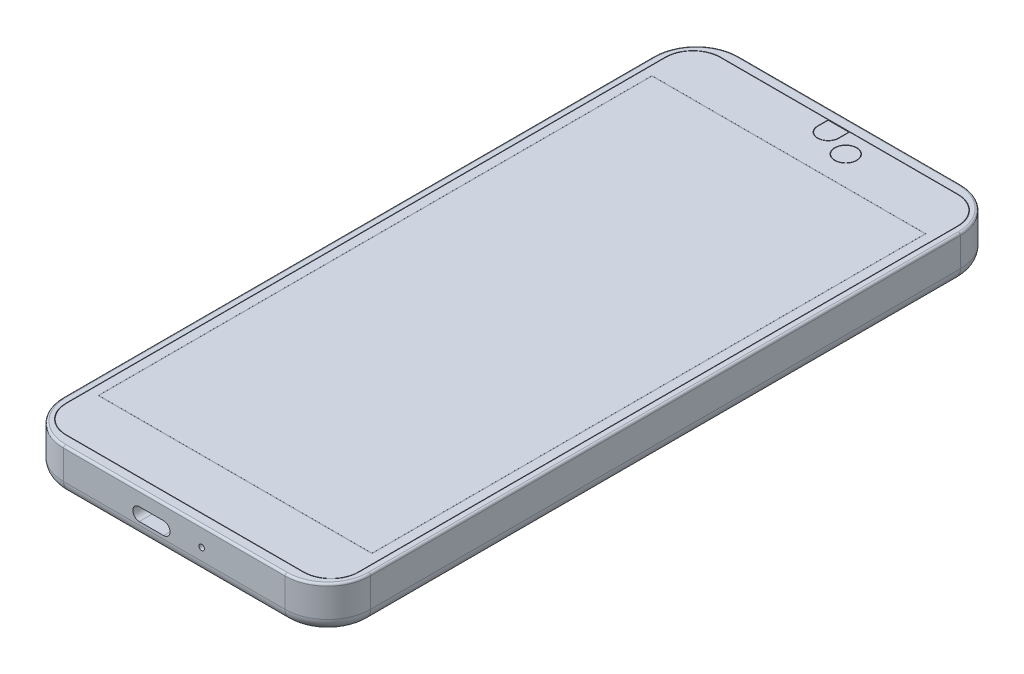
from build123d import *

# Parameters (mm, degrees)
SKIZZE1_W                            = 71.8
SKIZZE1_H                            = 158
AUFSATZ_LINEAR_AUSTRAGEN1_DEPTH      = 10.25
VERRUNDUNG1_R                        = 10
VERRUNDUNG2_R                        = 3
VERRUNDUNG3_R                        = 0.5
SCHNITT_LINEAR_AUSTRAGEN_D_NN1_DEPTH = 0.5
SCHNITT_LINEAR_AUSTRAGEN_D_NN2_DEPTH = 0.5
SKIZZE4_R                            = 2.6
SKIZZE4_R_2                          = 2.5
SCHNITT_LINEAR_AUSTRAGEN_D_NN3_DEPTH = 0.5
AUFSATZ_LINEAR_AUSTRAGEN2_DEPTH      = 0.5
SKIZZE6_R                            = 1.875
SKIZZE6_R_2                          = 0.65
SCHNITT_LINEAR_AUSTRAGEN1_DEPTH      = 25
SKIZZE7_R                            = 0.65
SCHNITT_LINEAR_AUSTRAGEN2_DEPTH      = 7
SKIZZE8_R                            = 5.25
SCHNITT_LINEAR_AUSTRAGEN3_DEPTH      = 0.9
FASE1_SIZE                           = 0.8
SCHNITT_LINEAR_AUSTRAGEN4_DEPTH      = 0.3
FASE2_SIZE                           = 0.2
SKIZZE10_W                           = 64.08
SKIZZE10_H                           = 129.6
SKIZZE10_W_2                         = 63.88
SKIZZE10_H_2                         = 129.4
SCHNITT_LINEAR_AUSTRAGEN_D_NN4_DEPTH = 0.01
SCHNITT_LINEAR_AUSTRAGEN5_DEPTH      = 2


with BuildPart() as part:
    # Skizze1 → Aufsatz-Linear austragen1 (new body)
    with BuildSketch(Plane(origin=(0, 0, 0), x_dir=(1, 0, 0), z_dir=(0, 1, 0))):
        Rectangle(SKIZZE1_W, SKIZZE1_H)
    extrude(amount=AUFSATZ_LINEAR_AUSTRAGEN1_DEPTH)

    # Verrundung1
    verrundung1_edges = [part.edges().sort_by_distance(p)[0] for p in [
        (35.9, 5.125, 79),
        (-35.9, 5.125, 79),
        (-35.9, 5.125, -79),
        (35.9, 5.125, -79),
    ]]
    fillet(verrundung1_edges, radius=VERRUNDUNG1_R)

    # Verrundung2
    verrundung2_edges = [part.edges().sort_by_distance(p)[0] for p in [
        (-35.9, 0, 0),
        (35.9, 0, 0),
        (0, 0, 79),
        (0, 0, -79),
        (32.971067812, 0, 76.071067812),
        (-32.971067812, 0, 76.071067812),
        (32.971067812, 0, -76.071067812),
        (-32.971067812, 0, -76.071067812),
    ]]
    fillet(verrundung2_edges, radius=VERRUNDUNG2_R)

    # Verrundung3
    verrundung3_edges = [part.edges().sort_by_distance(p)[0] for p in [
        (-35.9, 10.25, 0),
        (0, 10.25, -79),
        (35.9, 10.25, 0),
        (0, 10.25, 79),
        (32.971067812, 10.25, 76.071067812),
        (-32.971067812, 10.25, 76.071067812),
        (32.971067812, 10.25, -76.071067812),
        (-32.971067812, 10.25, -76.071067812),
    ]]
    fillet(verrundung3_edges, radius=VERRUNDUNG3_R)

    # Skizze2 → Schnitt-Linear-Austragen-Dünn1 (cut)
    with BuildSketch(Plane(origin=(0, 10.25, 0), x_dir=(1, 0, 0), z_dir=(0, 1, 0))):
        with BuildLine():
            Line((-27.75, 76.575), (27.75, 76.575))
            ThreePointArc((27.75, 76.575), (32.346194078, 74.671194078), (34.25, 70.075))
            Line((34.25, 70.075), (34.25, -70.075))
            ThreePointArc((34.25, -70.075), (32.346194078, -74.671194078), (27.75, -76.575))
            Line((27.75, -76.575), (-27.75, -76.575))
            ThreePointArc((-27.75, -76.575), (-32.346194078, -74.671194078), (-34.25, -70.075))
            Line((-34.25, -70.075), (-34.25, 70.075))
            ThreePointArc((-34.25, 70.075), (-32.346194078, 74.671194078), (-27.75, 76.575))
        make_face()
        with BuildLine():
            Line((-27.75, 76.475), (27.75, 76.475))
            ThreePointArc((27.75, 76.475), (32.2754834, 74.6004834), (34.15, 70.075))
            Line((34.15, 70.075), (34.15, -70.075))
            ThreePointArc((34.15, -70.075), (32.2754834, -74.6004834), (27.75, -76.475))
            Line((27.75, -76.475), (-27.75, -76.475))
            ThreePointArc((-27.75, -76.475), (-32.2754834, -74.6004834), (-34.15, -70.075))
            Line((-34.15, -70.075), (-34.15, 70.075))
            ThreePointArc((-34.15, 70.075), (-32.2754834, 74.6004834), (-27.75, 76.475))
        make_face(mode=Mode.SUBTRACT)
    extrude(amount=-SCHNITT_LINEAR_AUSTRAGEN_D_NN1_DEPTH, mode=Mode.SUBTRACT)

    # Skizze3 → Schnitt-Linear-Austragen-Dünn2 (cut)
    with BuildSketch(Plane(origin=(0, 10.25, 0), x_dir=(1, 0, 0), z_dir=(0, 1, 0))):
        with BuildLine():
            Line((-0.01, 71.475), (0.01, 71.475))
            ThreePointArc((0.01, 71.475), (1.770695885, 72.204304115), (2.5, 73.965))
            Line((2.5, 73.965), (2.5, 76.475))
            Line((2.5, 76.475), (-2.5, 76.475))
            Line((-2.5, 76.475), (-2.5, 73.965))
            ThreePointArc((-2.5, 73.965), (-1.770695885, 72.204304115), (-0.01, 71.475))
        make_face()
        with BuildLine():
            Line((-0.01, 71.575), (0.01, 71.575))
            ThreePointArc((0.01, 71.575), (1.699985207, 72.275014793), (2.4, 73.965))
            Line((2.4, 73.965), (2.4, 76.375))
            Line((2.4, 76.375), (-2.4, 76.375))
            Line((-2.4, 76.375), (-2.4, 73.965))
            ThreePointArc((-2.4, 73.965), (-1.699985207, 72.275014793), (-0.01, 71.575))
        make_face(mode=Mode.SUBTRACT)
    extrude(amount=-SCHNITT_LINEAR_AUSTRAGEN_D_NN2_DEPTH, mode=Mode.SUBTRACT)

    # Skizze4 → Schnitt-Linear-Austragen-Dünn3 (cut)
    with BuildSketch(Plane(origin=(0, 10.25, 0), x_dir=(1, 0, 0), z_dir=(0, 1, 0))):
        with Locations((6.5, 71.575)):
            Circle(SKIZZE4_R)
        with Locations((6.5, 71.575)):
            Circle(SKIZZE4_R_2, mode=Mode.SUBTRACT)
    extrude(amount=-SCHNITT_LINEAR_AUSTRAGEN_D_NN3_DEPTH, mode=Mode.SUBTRACT)

    # Skizze5 → Aufsatz-Linear austragen2 (add)
    with BuildSketch(Plane.ZY.offset(35.9)):
        with BuildLine():
            Line((-45.7, 4.61), (-36.1, 4.61))
            Line((-36.1, 4.61), (-36.1, 7.25))
            Line((-36.1, 7.25), (-45.7, 7.25))
            ThreePointArc((-45.7, 7.25), (-46.619238816, 6.869238816), (-47, 5.95))
            Line((-47, 5.95), (-47, 5.91))
            ThreePointArc((-47, 5.91), (-46.619238816, 4.990761184), (-45.7, 4.61))
        make_face()
        with BuildLine():
            Line((-24.2, 7.25), (-33.8, 7.25))
            Line((-33.8, 7.25), (-33.8, 4.61))
            Line((-33.8, 4.61), (-24.2, 4.61))
            ThreePointArc((-24.2, 4.61), (-23.280761184, 4.990761184), (-22.9, 5.91))
            Line((-22.9, 5.91), (-22.9, 5.95))
            ThreePointArc((-22.9, 5.95), (-23.280761184, 6.869238816), (-24.2, 7.25))
        make_face()
        with BuildLine():
            Line((-5.5, 7.25), (-13.95, 7.25))
            ThreePointArc((-13.95, 7.25), (-14.869238816, 6.869238816), (-15.25, 5.95))
            Line((-15.25, 5.95), (-15.25, 5.91))
            ThreePointArc((-15.25, 5.91), (-14.869238816, 4.990761184), (-13.95, 4.61))
            Line((-13.95, 4.61), (-5.5, 4.61))
            ThreePointArc((-5.5, 4.61), (-4.580761184, 4.990761184), (-4.2, 5.91))
            Line((-4.2, 5.91), (-4.2, 5.95))
            ThreePointArc((-4.2, 5.95), (-4.580761184, 6.869238816), (-5.5, 7.25))
        make_face()
    extrude(amount=AUFSATZ_LINEAR_AUSTRAGEN2_DEPTH)

    # Skizze6 → Schnitt-Linear austragen1 (cut)
    with BuildSketch(Plane(origin=(0, 0, -79), x_dir=(-1, 0, 0), z_dir=(0, 0, -1))):
        with Locations((23.4, 4.55)):
            Circle(SKIZZE6_R)
        with Locations((12.4, 6)):
            Circle(SKIZZE6_R_2)
    extrude(amount=-SCHNITT_LINEAR_AUSTRAGEN1_DEPTH, mode=Mode.SUBTRACT)

    # Skizze7 → Schnitt-Linear austragen2 (cut)
    with BuildSketch(Plane.XY.offset(79)):
        with Locations((6.4, 5.8)):
            Circle(SKIZZE7_R)
        with BuildLine():
            Line((-8.2, 6.75), (-2.5, 6.75))
            ThreePointArc((-2.5, 6.75), (-1, 5.25), (-2.5, 3.75))
            Line((-2.5, 3.75), (-8.2, 3.75))
            ThreePointArc((-8.2, 3.75), (-9.7, 5.25), (-8.2, 6.75))
        make_face()
    extrude(amount=-SCHNITT_LINEAR_AUSTRAGEN2_DEPTH, mode=Mode.SUBTRACT)

    # Skizze8 → Schnitt-Linear austragen3 (cut)
    with BuildSketch(Plane.XZ):
        with Locations(Location((0, -55.5, 0), (0, 0, 270))):
            Circle(SKIZZE8_R)
    extrude(amount=-SCHNITT_LINEAR_AUSTRAGEN3_DEPTH, mode=Mode.SUBTRACT)

    # Fase1
    fase1_edges = [part.edges().sort_by_distance(p)[0] for p in [
        (0, 0, -50.25),
    ]]
    chamfer(fase1_edges, length=FASE1_SIZE)

    # Skizze9 → Schnitt-Linear austragen4 (cut)
    with BuildSketch(Plane.XZ):
        with BuildLine():
            Line((25.4, -74.5), (16.5, -74.5))
            ThreePointArc((16.5, -74.5), (11, -69), (16.5, -63.5))
            Line((16.5, -63.5), (25.4, -63.5))
            ThreePointArc((25.4, -63.5), (30.9, -69), (25.4, -74.5))
        make_face()
    extrude(amount=-SCHNITT_LINEAR_AUSTRAGEN4_DEPTH, mode=Mode.SUBTRACT)

    # Fase2
    fase2_edges = [part.edges().sort_by_distance(p)[0] for p in [
        (30.9, 0, -69),
        (20.95, 0, -63.5),
        (11, 0, -69),
        (20.95, 0, -74.5),
    ]]
    chamfer(fase2_edges, length=FASE2_SIZE)

    # Skizze10 → Schnitt-Linear-Austragen-Dünn4 (cut)
    with BuildSketch(Plane(origin=(0, 10.25, 0), x_dir=(1, 0, 0), z_dir=(0, 1, 0))):
        Rectangle(SKIZZE10_W, SKIZZE10_H)
        Rectangle(SKIZZE10_W_2, SKIZZE10_H_2, mode=Mode.SUBTRACT)
    extrude(amount=-SCHNITT_LINEAR_AUSTRAGEN_D_NN4_DEPTH, mode=Mode.SUBTRACT)

    # Skizze11 → Schnitt-Linear austragen5 (cut)
    with BuildSketch(Plane.ZY.offset(35.9)):
        with BuildLine():
            Line((56.1, 6.25), (60.9, 6.25))
            ThreePointArc((60.9, 6.25), (61.8, 5.35), (60.9, 4.45))
            Line((60.9, 4.45), (56.1, 4.45))
            ThreePointArc((56.1, 4.45), (55.2, 5.35), (56.1, 6.25))
        make_face()
        with BuildLine():
            Line((63.55, 6.25), (68.35, 6.25))
            ThreePointArc((68.35, 6.25), (69.25, 5.35), (68.35, 4.45))
            Line((68.35, 4.45), (63.55, 4.45))
            ThreePointArc((63.55, 4.45), (62.65, 5.35), (63.55, 6.25))
        make_face()
        with BuildLine():
            Line((41.55, 4.3), (48.9, 4.3))
            ThreePointArc((48.9, 4.3), (49.819238816, 3.919238816), (50.2, 3))
            Line((50.2, 3), (49.680384758, 2.7))
            Line((49.680384758, 2.7), (40.769615242, 2.7))
            Line((40.769615242, 2.7), (40.25, 3))
            ThreePointArc((40.25, 3), (40.630761184, 3.919238816), (41.55, 4.3))
        make_face()
    extrude(amount=-SCHNITT_LINEAR_AUSTRAGEN5_DEPTH, mode=Mode.SUBTRACT)


solid = part.part
